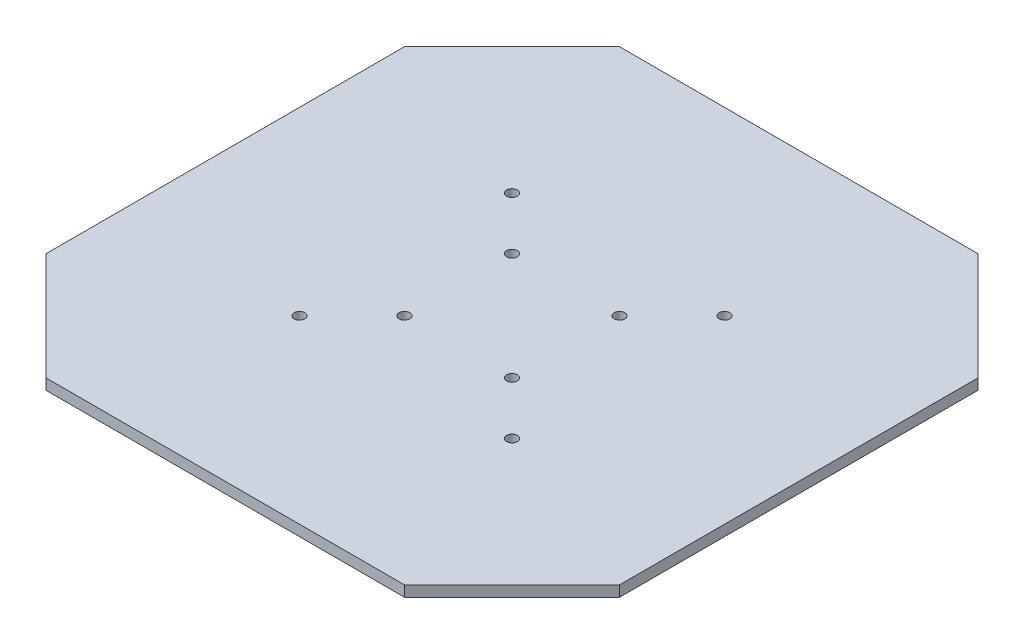
from build123d import *

# Parameters (mm, degrees)
BOSS_EXTRUDE1_DEPTH = 3
SKETCH3_R           = 1.5
CUT_EXTRUDE1_DEPTH  = 10


with BuildPart() as part:
    # Sketch1 → Boss-Extrude1 (new body)
    with BuildSketch(Plane(origin=(0, 0, 0), x_dir=(1, 0, 0), z_dir=(0, 1, 0))):
        Polygon((0, 130), (30, 160), (130, 160), (160, 130), (160, 30), (130, 0), (30, 0), (0, 30), align=None)
    extrude(amount=BOSS_EXTRUDE1_DEPTH)

    # Sketch3 → Cut-Extrude1 (cut)
    with BuildSketch(Plane.XZ):
        with BuildLine():
            ThreePointArc((49.294678888, -49.294678888), (49.294678888, -51.415999231), (51.415999231, -51.415999231))
            Line((51.415999231, -51.415999231), (49.294678888, -49.294678888))
        make_face()
        with BuildLine():
            Line((49.294678888, -49.294678888), (51.415999231, -51.415999231))
            ThreePointArc((51.415999231, -51.415999231), (51.741158358, -50.929364208), (51.855339059, -50.355339059))
            ThreePointArc((51.855339059, -50.355339059), (50.929364208, -48.969519761), (49.294678888, -49.294678888))
        make_face()
        with BuildLine():
            ThreePointArc((110.705321112, -49.294678888), (108.584000769, -49.294678888), (108.584000769, -51.415999231))
            Line((108.584000769, -51.415999231), (110.705321112, -49.294678888))
        make_face()
        with BuildLine():
            Line((110.705321112, -49.294678888), (108.584000769, -51.415999231))
            ThreePointArc((108.584000769, -51.415999231), (110.218686089, -51.741158358), (111.144660941, -50.355339059))
            ThreePointArc((111.144660941, -50.355339059), (111.030480239, -49.781313911), (110.705321112, -49.294678888))
        make_face()
        with BuildLine():
            ThreePointArc((111.144660941, -109.644660941), (110.218686089, -108.258841642), (108.584000769, -108.584000769))
            Line((108.584000769, -108.584000769), (110.705321112, -110.705321112))
            ThreePointArc((110.705321112, -110.705321112), (111.030480239, -110.218686089), (111.144660941, -109.644660941))
        make_face()
        with BuildLine():
            Line((110.705321112, -110.705321112), (108.584000769, -108.584000769))
            ThreePointArc((108.584000769, -108.584000769), (108.584000769, -110.705321112), (110.705321112, -110.705321112))
        make_face()
        with BuildLine():
            ThreePointArc((51.415999231, -108.584000769), (49.294678888, -108.584000769), (49.294678888, -110.705321112))
            Line((49.294678888, -110.705321112), (51.415999231, -108.584000769))
        make_face()
        with BuildLine():
            Line((51.415999231, -108.584000769), (49.294678888, -110.705321112))
            ThreePointArc((49.294678888, -110.705321112), (50.929364208, -111.030480239), (51.855339059, -109.644660941))
            ThreePointArc((51.855339059, -109.644660941), (51.741158358, -109.070635792), (51.415999231, -108.584000769))
        make_face()
        with Locations((65, -95)):
            Circle(SKETCH3_R)
        with Locations((95, -95)):
            Circle(SKETCH3_R)
        with Locations((65, -65)):
            Circle(SKETCH3_R)
        with Locations((95, -65)):
            Circle(SKETCH3_R)
    extrude(amount=-CUT_EXTRUDE1_DEPTH, mode=Mode.SUBTRACT)


solid = part.part
